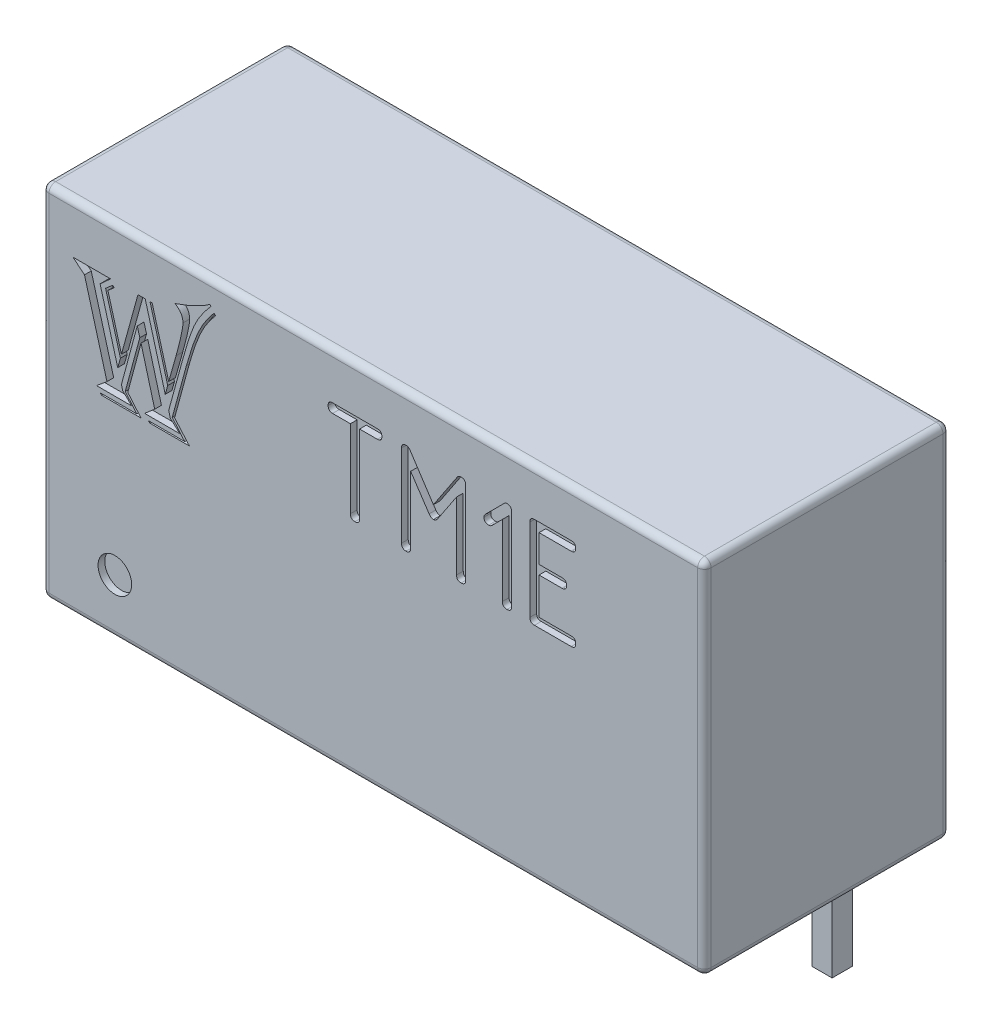
from build123d import *

# Parameters (mm, degrees)
SKETCH_2_W                         = 19.7
SKETCH_2_H                         = 7.3
EXTRUDE_1_DEPTH                    = 10.7
FILLET_1_R                         = 0.2
SKETCH_3_W                         = 0.6
SKETCH_3_H                         = 0.6
EXTRUDE_2_DEPTH                    = 4
CHAMFER_1_SIZE                     = 0.2
SKETCH_4_R                         = 0.5
CUT_EXTRUDE_1_DEPTH                = 0.2
PATTERN_LINEAR_2_COUNT             = 7
PATTERN_LINEAR_2_PITCH             = 2.54
CHAMFER_1_OF_PATTERN_LINEAR_2_SIZE = 0.2


with BuildPart() as part:
    # Эскиз2 → Бобышка-Вытянуть1 (new body)
    with BuildSketch(Plane(origin=(0, 0, 0), x_dir=(1, 0, 0), z_dir=(0, 1, 0))):
        Rectangle(SKETCH_2_W, SKETCH_2_H)
    extrude(amount=EXTRUDE_1_DEPTH)

    # Скругление1
    fillet_1_edges = [part.edges().sort_by_distance(p)[0] for p in [
        (-9.85, 10.7, 0),
        (0, 10.7, 3.65),
        (9.85, 10.7, 0),
        (0, 0, 3.65),
        (-9.85, 0, 0),
        (0, 0, -3.65),
        (9.85, 0, 0),
        (9.85, 5.35, 3.65),
        (-9.85, 5.35, 3.65),
        (-9.85, 5.35, -3.65),
        (9.85, 5.35, -3.65),
        (0, 10.7, -3.65),
    ]]
    fillet(fillet_1_edges, radius=FILLET_1_R)

    # Эскиз3 → Бобышка-Вытянуть2 (add)
    with BuildSketch(Plane.XZ):
        with Locations((-7.62, -2.38)):
            Rectangle(SKETCH_3_W, SKETCH_3_H)
    extrude_2 = extrude(amount=EXTRUDE_2_DEPTH)

    # Фаска1
    chamfer_1_edges = [part.edges().sort_by_distance(p)[0] for p in [
        (-7.32, -4, -2.38),
        (-7.62, -4, -2.08),
        (-7.92, -4, -2.38),
        (-7.62, -4, -2.68),
    ]]
    chamfer(chamfer_1_edges, length=CHAMFER_1_SIZE)

    # Эскиз4 → Вырез-Вытянуть1 (cut)
    with BuildSketch(Plane.XY.offset(3.65)):
        with Locations((-7.68950771, 1.64626856)):
            Circle(SKETCH_4_R)
        with BuildLine():
            add(Edge.make_bspline(
                [(-1.344415696, 9.182310933), (-1.344266371, 9.193129492), (-1.343986736, 9.213388959), (-1.336681075, 9.241435642), (-1.326921273, 9.26575643), (-1.311444221, 9.285324961), (-1.292475351, 9.300936794), (-1.268648064, 9.311266733), (-1.241271796, 9.318161675), (-1.221437304, 9.318538886), (-1.211035133, 9.318736714)],
                knots=[0, 0, 0, 0, 3.2331e-05, 6.0545e-05, 8.6456e-05, 0.000110333, 0.000134588, 0.000159388, 0.000187602, 0.000218717, 0.000218717, 0.000218717, 0.000218717], degree=3))
            Line((-1.211035133, 9.318736714), (0.120334321, 9.318736714))
            add(Edge.make_bspline(
                [(0.120334321, 9.318736714), (0.130736492, 9.318538886), (0.150570984, 9.318161675), (0.177947252, 9.311266733), (0.201774539, 9.300936794), (0.220743409, 9.285324961), (0.236220461, 9.26575643), (0.245980263, 9.241435642), (0.253285924, 9.213388959), (0.253565559, 9.193129492), (0.253714884, 9.182310933)],
                knots=[0, 0, 0, 0, 3.1115e-05, 5.9329e-05, 8.4128e-05, 0.000108383, 0.00013226, 0.000158172, 0.000186386, 0.000218717, 0.000218717, 0.000218717, 0.000218717], degree=3))
            add(Edge.make_bspline(
                [(0.253714884, 9.182310933), (0.253506721, 9.17171488), (0.253109537, 9.151497117), (0.246333588, 9.12341959), (0.235713285, 9.099568196), (0.22185524, 9.079051623), (0.201809069, 9.064416978), (0.178574078, 9.053182874), (0.150844395, 9.047403413), (0.131318327, 9.046411953), (0.120943365, 9.045885152)],
                knots=[0, 0, 0, 0, 3.1723e-05, 6.0529e-05, 8.5883e-05, 0.000109884, 0.000133761, 0.00015937, 0.000186852, 0.000218008, 0.000218008, 0.000218008, 0.000218008], degree=3))
            Line((0.120943365, 9.045885152), (-0.408924625, 9.045885152))
            Line((-0.408924625, 9.045885152), (-0.408924625, 6.72664687))
            add(Edge.make_bspline(
                [(-0.408924625, 6.72664687), (-0.409123847, 6.716043968), (-0.409503971, 6.695813136), (-0.416394271, 6.667823212), (-0.426740296, 6.643462653), (-0.442105441, 6.623772633), (-0.462083172, 6.60851704), (-0.485959175, 6.597567407), (-0.514423766, 6.591685723), (-0.534564433, 6.590731895), (-0.545350406, 6.590221089)],
                knots=[0, 0, 0, 0, 3.1723e-05, 6.0529e-05, 8.5883e-05, 0.000110615, 0.000134492, 0.000160653, 0.000188728, 0.000221099, 0.000221099, 0.000221099, 0.000221099], degree=3))
            add(Edge.make_bspline(
                [(-0.545350406, 6.590221089), (-0.555918226, 6.590781231), (-0.576024672, 6.591846963), (-0.604480113, 6.59725932), (-0.628120025, 6.60893511), (-0.648683127, 6.623314149), (-0.663062166, 6.643877251), (-0.674737957, 6.667517163), (-0.680150313, 6.695972604), (-0.681216045, 6.71607905), (-0.681776187, 6.72664687)],
                knots=[0, 0, 0, 0, 3.1764e-05, 6.0434e-05, 8.6043e-05, 0.000110405, 0.000134767, 0.000160375, 0.000189046, 0.00022081, 0.00022081, 0.00022081, 0.00022081], degree=3))
            Line((-0.681776187, 6.72664687), (-0.681776187, 9.045885152))
            Line((-0.681776187, 9.045885152), (-1.211644177, 9.045885152))
            add(Edge.make_bspline(
                [(-1.211644177, 9.045885152), (-1.222023494, 9.046407076), (-1.241557759, 9.047389358), (-1.269232727, 9.053230086), (-1.292506804, 9.064188778), (-1.311913095, 9.079465695), (-1.326531785, 9.099322772), (-1.336982453, 9.123461798), (-1.343825637, 9.151484696), (-1.34421279, 9.171710608), (-1.344415696, 9.182310933)],
                knots=[0, 0, 0, 0, 3.1157e-05, 5.8638e-05, 8.4247e-05, 0.000107645, 0.000132007, 0.000157361, 0.000186167, 0.00021789, 0.00021789, 0.00021789, 0.00021789], degree=3))
        make_face()
        with BuildLine():
            add(Edge.make_bspline(
                [(2.606450567, 9.318736714), (2.617669629, 9.318576919), (2.638720347, 9.318277089), (2.667824437, 9.311110872), (2.693144867, 9.301121042), (2.713485255, 9.285547476), (2.729569615, 9.265798265), (2.740193363, 9.241587062), (2.747131706, 9.213345923), (2.747930786, 9.193118581), (2.748357741, 9.182310933)],
                knots=[0, 0, 0, 0, 3.3547e-05, 6.2946e-05, 8.9416e-05, 0.000114631, 0.000138886, 0.000165047, 0.00019326, 0.000225632, 0.000225632, 0.000225632, 0.000225632], degree=3))
            Line((2.748357741, 9.182310933), (2.748357741, 6.72664687))
            add(Edge.make_bspline(
                [(2.748357741, 6.72664687), (2.748158519, 6.716043968), (2.747778395, 6.695813136), (2.740888096, 6.667823212), (2.730542071, 6.643462653), (2.715176925, 6.623772633), (2.695199194, 6.60851704), (2.671323191, 6.597567407), (2.6428586, 6.591685723), (2.622717933, 6.590731895), (2.61193196, 6.590221089)],
                knots=[0, 0, 0, 0, 3.1723e-05, 6.0529e-05, 8.5883e-05, 0.000110615, 0.000134492, 0.000160653, 0.000188728, 0.000221099, 0.000221099, 0.000221099, 0.000221099], degree=3))
            add(Edge.make_bspline(
                [(2.61193196, 6.590221089), (2.60136414, 6.590781231), (2.581257694, 6.591846963), (2.552802253, 6.59725932), (2.529162341, 6.60893511), (2.508599239, 6.623314149), (2.4942202, 6.643877251), (2.482544409, 6.667517163), (2.477132053, 6.695972604), (2.476066321, 6.71607905), (2.475506179, 6.72664687)],
                knots=[0, 0, 0, 0, 3.1764e-05, 6.0434e-05, 8.6043e-05, 0.000110405, 0.000134767, 0.000160375, 0.000189046, 0.00022081, 0.00022081, 0.00022081, 0.00022081], degree=3))
            Line((2.475506179, 6.72664687), (2.475506179, 8.735881925))
            Line((2.475506179, 8.735881925), (1.914576962, 7.892356448))
            add(Edge.make_bspline(
                [(1.914576962, 7.892356448), (1.905513698, 7.880139294), (1.888429366, 7.857109852), (1.857007015, 7.831168606), (1.823574717, 7.81407926), (1.800056553, 7.812251431), (1.788504923, 7.81135364)],
                knots=[0, 0, 0, 0, 4.5467e-05, 8.5705e-05, 0.000121395, 0.000155848, 0.000155848, 0.000155848, 0.000155848], degree=3))
            add(Edge.make_bspline(
                [(1.788504923, 7.81135364), (1.776734522, 7.812206848), (1.752708122, 7.813948464), (1.719049141, 7.831724714), (1.687150721, 7.857888061), (1.669859252, 7.881134334), (1.660605753, 7.893574535)],
                knots=[0, 0, 0, 0, 3.5056e-05, 7.1558e-05, 0.000111796, 0.000158119, 0.000158119, 0.000158119, 0.000158119], degree=3))
            Line((1.660605753, 7.893574535), (1.111248366, 8.716392528))
            Line((1.111248366, 8.716392528), (1.111248366, 6.725428783))
            add(Edge.make_bspline(
                [(1.111248366, 6.725428783), (1.111077455, 6.714815847), (1.110754539, 6.694763922), (1.103618092, 6.66708591), (1.093665514, 6.642845738), (1.07762437, 6.623854615), (1.058501648, 6.607622349), (1.033912543, 6.597997839), (1.005911146, 6.590637278), (0.985644811, 6.590365968), (0.974822585, 6.590221089)],
                knots=[0, 0, 0, 0, 3.1723e-05, 5.9937e-05, 8.5291e-05, 0.000109546, 0.000133801, 0.000159712, 0.000187926, 0.000220257, 0.000220257, 0.000220257, 0.000220257], degree=3))
            add(Edge.make_bspline(
                [(0.974822585, 6.590221089), (0.964254765, 6.590781231), (0.944148319, 6.591846963), (0.915692878, 6.59725932), (0.892052966, 6.60893511), (0.871489864, 6.623314149), (0.857110825, 6.643877251), (0.845435034, 6.667517163), (0.840022678, 6.695972604), (0.838956946, 6.71607905), (0.838396804, 6.72664687)],
                knots=[0, 0, 0, 0, 3.1764e-05, 6.0434e-05, 8.6043e-05, 0.000110405, 0.000134767, 0.000160375, 0.000189046, 0.00022081, 0.00022081, 0.00022081, 0.00022081], degree=3))
            Line((0.838396804, 6.72664687), (0.838396804, 9.182310933))
            add(Edge.make_bspline(
                [(0.838396804, 9.182310933), (0.838541683, 9.193133159), (0.838812993, 9.213399494), (0.846173553, 9.241400891), (0.855798064, 9.265989995), (0.87203033, 9.285112718), (0.891021453, 9.301153861), (0.915261625, 9.311106439), (0.942939636, 9.318242887), (0.962991562, 9.318565803), (0.973604498, 9.318736714)],
                knots=[0, 0, 0, 0, 3.2331e-05, 6.0545e-05, 8.6456e-05, 0.000110711, 0.000134966, 0.00016032, 0.000188534, 0.000220257, 0.000220257, 0.000220257, 0.000220257], degree=3))
            add(Edge.make_bspline(
                [(0.973604498, 9.318736714), (0.985504795, 9.317966788), (1.008828614, 9.316457783), (1.041867726, 9.302846556), (1.070505811, 9.280141141), (1.085290544, 9.260254006), (1.092977056, 9.24991478)],
                knots=[0, 0, 0, 0, 3.5581e-05, 6.9736e-05, 0.000105312, 0.000143836, 0.000143836, 0.000143836, 0.000143836], degree=3))
            Line((1.092977056, 9.24991478), (1.78789588, 8.193833062))
            Line((1.78789588, 8.193833062), (2.486468965, 9.243824343))
            add(Edge.make_bspline(
                [(2.486468965, 9.243824343), (2.493345007, 9.255311321), (2.50648846, 9.277268509), (2.535883061, 9.300965274), (2.569561156, 9.316159129), (2.593899291, 9.317859715), (2.606450567, 9.318736714)],
                knots=[0, 0, 0, 0, 3.9868e-05, 7.6207e-05, 0.000111395, 0.000148865, 0.000148865, 0.000148865, 0.000148865], degree=3))
        make_face()
        with BuildLine():
            Line((3.839763991, 8.840637436), (3.526106503, 8.526979948))
            add(Edge.make_bspline(
                [(3.526106503, 8.526979948), (3.519416413, 8.521200608), (3.50631719, 8.509884636), (3.483013989, 8.498055965), (3.457663496, 8.491316969), (3.440068846, 8.490331081), (3.431095691, 8.489828284)],
                knots=[0, 0, 0, 0, 2.6443e-05, 5.1775e-05, 7.7629e-05, 0.000104537, 0.000104537, 0.000104537, 0.000104537], degree=3))
            add(Edge.make_bspline(
                [(3.431095691, 8.489828284), (3.420278474, 8.489978456), (3.400021518, 8.490259678), (3.371958271, 8.497554878), (3.347426415, 8.507456612), (3.327600262, 8.523019255), (3.312540198, 8.542865576), (3.301149602, 8.566563551), (3.295671858, 8.594956541), (3.294615881, 8.615072305), (3.294060866, 8.625645022)],
                knots=[0, 0, 0, 0, 3.2331e-05, 6.0545e-05, 8.6456e-05, 0.000111188, 0.000135065, 0.000160674, 0.000189345, 0.000221108, 0.000221108, 0.000221108, 0.000221108], degree=3))
            add(Edge.make_bspline(
                [(3.294060866, 8.625645022), (3.294485372, 8.6346376), (3.29531113, 8.652130152), (3.303093367, 8.67717001), (3.315355618, 8.700296731), (3.327055034, 8.713362982), (3.333039661, 8.72004679)],
                knots=[0, 0, 0, 0, 2.6908e-05, 5.2343e-05, 7.7959e-05, 0.000104784, 0.000104784, 0.000104784, 0.000104784], degree=3))
            Line((3.333039661, 8.72004679), (3.862907651, 9.24991478))
            add(Edge.make_bspline(
                [(3.862907651, 9.24991478), (3.871726947, 9.260180566), (3.888289661, 9.279459801), (3.916257816, 9.301814324), (3.945124742, 9.316008337), (3.964890628, 9.317852819), (3.974362642, 9.318736714)],
                knots=[0, 0, 0, 0, 4.0519e-05, 7.6094e-05, 0.000106892, 0.00013523, 0.00013523, 0.00013523, 0.00013523], degree=3))
            add(Edge.make_bspline(
                [(3.974362642, 9.318736714), (3.985176023, 9.318563884), (4.00562379, 9.318237067), (4.033918963, 9.311109122), (4.058686187, 9.301135266), (4.078401278, 9.285343804), (4.094409805, 9.265810799), (4.105226825, 9.241667435), (4.111163795, 9.213248116), (4.112109238, 9.193100583), (4.112615554, 9.182310933)],
                knots=[0, 0, 0, 0, 3.2331e-05, 6.1137e-05, 8.7048e-05, 0.00011178, 0.000136035, 0.000162196, 0.000190271, 0.000222642, 0.000222642, 0.000222642, 0.000222642], degree=3))
            Line((4.112615554, 9.182310933), (4.112615554, 6.72664687))
            add(Edge.make_bspline(
                [(4.112615554, 6.72664687), (4.112416332, 6.716043968), (4.112036207, 6.695813136), (4.105145908, 6.667823212), (4.094799883, 6.643462653), (4.079434738, 6.623772633), (4.059457007, 6.60851704), (4.035581004, 6.597567407), (4.007116412, 6.591685723), (3.986975746, 6.590731895), (3.976189773, 6.590221089)],
                knots=[0, 0, 0, 0, 3.1723e-05, 6.0529e-05, 8.5883e-05, 0.000110615, 0.000134492, 0.000160653, 0.000188728, 0.000221099, 0.000221099, 0.000221099, 0.000221099], degree=3))
            add(Edge.make_bspline(
                [(3.976189773, 6.590221089), (3.965587042, 6.590420385), (3.945356538, 6.590800651), (3.917364416, 6.597690003), (3.893011037, 6.608039124), (3.87329583, 6.623393409), (3.85824547, 6.643263681), (3.846852061, 6.666954711), (3.841375179, 6.695349831), (3.840319074, 6.715465277), (3.839763991, 6.726037827)],
                knots=[0, 0, 0, 0, 3.1723e-05, 6.0529e-05, 8.5883e-05, 0.000110615, 0.000134492, 0.000160101, 0.000188771, 0.000220535, 0.000220535, 0.000220535, 0.000220535], degree=3))
            Line((3.839763991, 6.726037827), (3.839763991, 8.840637436))
        make_face()
        with BuildLine():
            Line((4.658318679, 6.72664687), (4.658318679, 9.182310933))
            add(Edge.make_bspline(
                [(4.658318679, 9.182310933), (4.658829485, 9.193096906), (4.659783313, 9.213237573), (4.665664997, 9.241702164), (4.67661463, 9.265578167), (4.691870222, 9.285555898), (4.711560243, 9.300921043), (4.735920802, 9.311267068), (4.763910726, 9.318157368), (4.784141557, 9.318537492), (4.79474446, 9.318736714)],
                knots=[0, 0, 0, 0, 3.2371e-05, 6.0447e-05, 8.6607e-05, 0.000110484, 0.000135216, 0.000160571, 0.000189376, 0.000221099, 0.000221099, 0.000221099, 0.000221099], degree=3))
            Line((4.79474446, 9.318736714), (5.88615071, 9.318736714))
            add(Edge.make_bspline(
                [(5.88615071, 9.318736714), (5.896973084, 9.318591896), (5.917239696, 9.318320701), (5.945239267, 9.310959386), (5.969834442, 9.301337384), (5.988936251, 9.285096473), (6.005177161, 9.265994664), (6.014799163, 9.24139949), (6.022160478, 9.213399919), (6.022431673, 9.193133307), (6.022576491, 9.182310933)],
                knots=[0, 0, 0, 0, 3.2331e-05, 6.0545e-05, 8.6456e-05, 0.000110711, 0.000134966, 0.000160877, 0.000189091, 0.000221422, 0.000221422, 0.000221422, 0.000221422], degree=3))
            add(Edge.make_bspline(
                [(6.022576491, 9.182310933), (6.022377269, 9.17170803), (6.021997145, 9.151477198), (6.015106846, 9.123487274), (6.004760821, 9.099126715), (5.989395675, 9.079436695), (5.969417944, 9.064181102), (5.945541941, 9.053231469), (5.91707735, 9.047349786), (5.896936683, 9.046395957), (5.88615071, 9.045885152)],
                knots=[0, 0, 0, 0, 3.1723e-05, 6.0529e-05, 8.5883e-05, 0.000110615, 0.000134492, 0.000160653, 0.000188728, 0.000221099, 0.000221099, 0.000221099, 0.000221099], degree=3))
            Line((5.88615071, 9.045885152), (4.931170241, 9.045885152))
            Line((4.931170241, 9.045885152), (4.931170241, 8.227330464))
            Line((4.931170241, 8.227330464), (5.613299148, 8.227330464))
            add(Edge.make_bspline(
                [(5.613299148, 8.227330464), (5.624121522, 8.227185646), (5.644388133, 8.226914451), (5.672387705, 8.219553136), (5.696982879, 8.209931134), (5.716084688, 8.193690223), (5.732325598, 8.174588414), (5.7419476, 8.14999324), (5.749308915, 8.121993669), (5.749580111, 8.101727057), (5.749724929, 8.090904683)],
                knots=[0, 0, 0, 0, 3.2331e-05, 6.0545e-05, 8.6456e-05, 0.000110711, 0.000134966, 0.000160877, 0.000189091, 0.000221422, 0.000221422, 0.000221422, 0.000221422], degree=3))
            add(Edge.make_bspline(
                [(5.749724929, 8.090904683), (5.749525707, 8.08030178), (5.749145582, 8.060070948), (5.742255283, 8.032081024), (5.731909258, 8.007720465), (5.716544113, 7.988030445), (5.696566382, 7.972774852), (5.672690379, 7.961825219), (5.644225787, 7.955943536), (5.624085121, 7.954989707), (5.613299148, 7.954478902)],
                knots=[0, 0, 0, 0, 3.1723e-05, 6.0529e-05, 8.5883e-05, 0.000110615, 0.000134492, 0.000160653, 0.000188728, 0.000221099, 0.000221099, 0.000221099, 0.000221099], degree=3))
            Line((5.613299148, 7.954478902), (4.931170241, 7.954478902))
            Line((4.931170241, 7.954478902), (4.931170241, 6.863072652))
            Line((4.931170241, 6.863072652), (5.88615071, 6.863072652))
            add(Edge.make_bspline(
                [(5.88615071, 6.863072652), (5.896973084, 6.862927833), (5.917239696, 6.862656638), (5.945239267, 6.855295323), (5.969834442, 6.845673321), (5.988936251, 6.829432411), (6.005177161, 6.810330602), (6.014799163, 6.785735427), (6.022160478, 6.757735856), (6.022431673, 6.737469244), (6.022576491, 6.72664687)],
                knots=[0, 0, 0, 0, 3.2331e-05, 6.0545e-05, 8.6456e-05, 0.000110711, 0.000134966, 0.000160877, 0.000189091, 0.000221422, 0.000221422, 0.000221422, 0.000221422], degree=3))
            add(Edge.make_bspline(
                [(6.022576491, 6.72664687), (6.022377269, 6.716043968), (6.021997145, 6.695813136), (6.015106846, 6.667823212), (6.004760821, 6.643462653), (5.989395675, 6.623772633), (5.969417944, 6.60851704), (5.945541941, 6.597567407), (5.91707735, 6.591685723), (5.896936683, 6.590731895), (5.88615071, 6.590221089)],
                knots=[0, 0, 0, 0, 3.1723e-05, 6.0529e-05, 8.5883e-05, 0.000110615, 0.000134492, 0.000160653, 0.000188728, 0.000221099, 0.000221099, 0.000221099, 0.000221099], degree=3))
            Line((5.88615071, 6.590221089), (4.79474446, 6.590221089))
            add(Edge.make_bspline(
                [(4.79474446, 6.590221089), (4.78417664, 6.590781231), (4.764070194, 6.591846963), (4.735614753, 6.59725932), (4.711974841, 6.60893511), (4.691411739, 6.623314149), (4.6770327, 6.643877251), (4.665356909, 6.667517163), (4.659944553, 6.695972604), (4.658878821, 6.71607905), (4.658318679, 6.72664687)],
                knots=[0, 0, 0, 0, 3.1764e-05, 6.0434e-05, 8.6043e-05, 0.000110405, 0.000134767, 0.000160375, 0.000189046, 0.00022081, 0.00022081, 0.00022081, 0.00022081], degree=3))
        make_face()
        with BuildLine():
            add(Edge.make_bspline(
                [(-4.826920529, 9.99808571), (-4.877635504, 9.940076399), (-4.976256976, 9.827270199), (-5.106321335, 9.650843506), (-5.218113707, 9.475770751), (-5.295816993, 9.325229448), (-5.351641753, 9.197924187), (-5.393852102, 9.088650364), (-5.439966404, 8.965985236), (-5.485301464, 8.828052847), (-5.534904487, 8.676531281), (-5.584495653, 8.510075747), (-5.637137079, 8.32973205), (-5.671825467, 8.204587794), (-5.689805925, 8.139720236)],
                knots=[0, 0, 0, 0, 0.000231072, 0.000449347, 0.000656859, 0.000853626, 0.000956844, 0.001073769, 0.001205006, 0.001349934, 0.001509276, 0.001683302, 0.001870948, 0.002072885, 0.002072885, 0.002072885, 0.002072885], degree=3))
            Line((-5.689805925, 8.139720236), (-6.08691, 6.690698346))
            Line((-6.08691, 6.690698346), (-6.041351827, 6.508465654))
            Line((-6.041351827, 6.508465654), (-5.758483171, 6.251435962))
            Line((-5.758483171, 6.251435962), (-6.804961204, 6.251435962))
            Line((-6.804961204, 6.251435962), (-6.504413256, 6.508465654))
            Line((-6.504413256, 6.508465654), (-6.91103695, 8.007125554))
            Line((-6.91103695, 8.007125554), (-7.305421134, 6.541104345))
            Line((-7.305421134, 6.541104345), (-6.91103695, 6.077362943))
            Line((-6.91103695, 6.077362943), (-8.083309938, 6.077362943))
            Line((-8.083309938, 6.077362943), (-8.129548084, 6.120881198))
            Line((-8.129548084, 6.120881198), (-7.036831905, 6.120881198))
            Line((-7.036831905, 6.120881198), (-7.38157808, 6.526824918))
            Line((-7.38157808, 6.526824918), (-6.947755477, 8.126800754))
            Line((-6.947755477, 8.126800754), (-7.02323245, 8.395389983))
            Line((-7.02323245, 8.395389983), (-7.49377358, 6.653299846))
            Line((-7.49377358, 6.653299846), (-7.457055053, 6.508465654))
            Line((-7.457055053, 6.508465654), (-7.188465824, 6.251435962))
            Line((-7.188465824, 6.251435962), (-8.236983775, 6.251435962))
            Line((-8.236983775, 6.251435962), (-7.924876292, 6.508465654))
            Line((-7.924876292, 6.508465654), (-8.593289486, 8.927128659))
            Line((-8.593289486, 8.927128659), (-8.937355688, 9.210677288))
            Line((-8.937355688, 9.210677288), (-7.814720709, 9.210677288))
            Line((-7.814720709, 9.210677288), (-8.129548084, 8.927128659))
            Line((-8.129548084, 8.927128659), (-7.603929163, 7.030004739))
            Line((-7.603929163, 7.030004739), (-7.52369238, 7.312873395))
            Line((-7.52369238, 7.312873395), (-7.966354628, 8.893130022))
            Line((-7.966354628, 8.893130022), (-7.757603, 9.075362714))
            Line((-7.757603, 9.075362714), (-7.704565127, 9.039324159))
            Line((-7.704565127, 9.039324159), (-7.895637464, 8.873410813))
            Line((-7.895637464, 8.873410813), (-7.49377358, 7.429828705))
            Line((-7.49377358, 7.429828705), (-7.002833268, 9.210677288))
            Line((-7.002833268, 9.210677288), (-6.78660194, 9.210677288))
            Line((-6.78660194, 9.210677288), (-6.190265855, 7.049043976))
            Line((-6.190265855, 7.049043976), (-6.1168288, 7.312873395))
            Line((-6.1168288, 7.312873395), (-6.644487639, 9.210677288))
            Line((-6.644487639, 9.210677288), (-6.580570202, 9.210677288))
            Line((-6.580570202, 9.210677288), (-6.08691, 7.429828705))
            Line((-6.08691, 7.429828705), (-5.868638753, 8.2029577))
            add(Edge.make_bspline(
                [(-5.868638753, 8.2029577), (-5.852399918, 8.260941423), (-5.821497941, 8.371282573), (-5.779709212, 8.529207611), (-5.745362849, 8.671530243), (-5.715577342, 8.797792909), (-5.6929154, 8.908429472), (-5.677234564, 9.003247309), (-5.666754945, 9.08193757), (-5.664820039, 9.129284849), (-5.663966961, 9.150159714)],
                knots=[0, 0, 0, 0, 0.000180644, 0.000343759, 0.000490044, 0.000619854, 0.000732938, 0.00082874, 0.000908189, 0.000970839, 0.000970839, 0.000970839, 0.000970839], degree=3))
            add(Edge.make_bspline(
                [(-5.663966961, 9.150159714), (-5.664444102, 9.170174469), (-5.665374575, 9.209205242), (-5.677832358, 9.265815606), (-5.696071493, 9.319093511), (-5.721278692, 9.369687349), (-5.755483305, 9.415862075), (-5.79548155, 9.459856387), (-5.843949079, 9.499529133), (-5.879944069, 9.522477437), (-5.898557553, 9.534344308)],
                knots=[0, 0, 0, 0, 5.9934e-05, 0.000116878, 0.000173003, 0.000228653, 0.000285645, 0.000344834, 0.000406648, 0.000472843, 0.000472843, 0.000472843, 0.000472843], degree=3))
            add(Edge.make_bspline(
                [(-5.898557553, 9.534344308), (-5.852854058, 9.549348083), (-5.759150323, 9.580109621), (-5.617782387, 9.635379725), (-5.471123362, 9.6968715), (-5.323941724, 9.764902592), (-5.183579625, 9.833679594), (-5.059185033, 9.901732221), (-4.953287658, 9.964804983), (-4.891923173, 10.009461396), (-4.863639056, 10.030044428)],
                knots=[0, 0, 0, 0, 0.000144284, 0.000295819, 0.000455195, 0.00062132, 0.000782187, 0.000923988, 0.00104667, 0.001151565, 0.001151565, 0.001151565, 0.001151565], degree=3))
            Line((-4.863639056, 10.030044428), (-4.826920529, 9.99808571))
        make_face()
        with BuildLine():
            add(Edge.make_bspline(
                [(-4.689566037, 9.823332718), (-4.734443021, 9.771697544), (-4.824111341, 9.66852574), (-4.94261163, 9.500409015), (-5.050747144, 9.324046548), (-5.130330435, 9.168024735), (-5.189103399, 9.034547574), (-5.233486576, 8.924608961), (-5.279663273, 8.805516723), (-5.323731783, 8.676286079), (-5.369498265, 8.538085097), (-5.415864969, 8.390388815), (-5.461873835, 8.232995082), (-5.491636742, 8.124577904), (-5.50689326, 8.069003072)],
                knots=[0, 0, 0, 0, 0.000205119, 0.000409846, 0.000616142, 0.000825366, 0.000934658, 0.001053604, 0.001181023, 0.00131779, 0.001463149, 0.001617778, 0.001782168, 0.001955059, 0.001955059, 0.001955059, 0.001955059], degree=3))
            Line((-5.50689326, 8.069003072), (-5.91283698, 6.581902709))
            Line((-5.91283698, 6.581902709), (-5.472214651, 6.077362943))
            Line((-5.472214651, 6.077362943), (-6.649247448, 6.077362943))
            Line((-6.649247448, 6.077362943), (-6.702285321, 6.120881198))
            Line((-6.702285321, 6.120881198), (-5.611609061, 6.120881198))
            Line((-5.611609061, 6.120881198), (-5.983554145, 6.558103664))
            Line((-5.983554145, 6.558103664), (-5.561291079, 8.10096179))
            add(Edge.make_bspline(
                [(-5.561291079, 8.10096179), (-5.545810979, 8.15653854), (-5.515744157, 8.26448463), (-5.469295995, 8.421058195), (-5.424003878, 8.568105942), (-5.378609024, 8.70501873), (-5.333606298, 8.831933995), (-5.289414087, 8.948917071), (-5.246347229, 9.056461553), (-5.187951552, 9.186555201), (-5.109367116, 9.341365894), (-5.001658755, 9.520549148), (-4.879052144, 9.695048433), (-4.787979013, 9.805989172), (-4.741923938, 9.862091164)],
                knots=[0, 0, 0, 0, 0.000173074, 0.00033616, 0.000489937, 0.00063465, 0.000768851, 0.00089388, 0.001009795, 0.001116325, 0.001321593, 0.001530216, 0.001743012, 0.001960709, 0.001960709, 0.001960709, 0.001960709], degree=3))
            Line((-4.741923938, 9.862091164), (-4.689566037, 9.823332718))
        make_face()
    extrude(amount=-CUT_EXTRUDE_1_DEPTH, mode=Mode.SUBTRACT)

    # Линейный массив2: Бобышка-Вытянуть2 ×7, 3 skipped
    with Locations(*[(i * PATTERN_LINEAR_2_PITCH, 0, 0) for i in range(1, PATTERN_LINEAR_2_COUNT) if i not in (2, 3, 5)]):
        add(extrude_2)

    # Фаска1 of Линейный массив2
    chamfer_1_of_pattern_linear_2_edges = [part.edges().sort_by_distance(p)[0] for p in [
        (-4.78, -4, -2.38),
        (-5.08, -4, -2.08),
        (-5.38, -4, -2.38),
        (-5.08, -4, -2.68),
        (2.84, -4, -2.38),
        (2.54, -4, -2.08),
        (2.24, -4, -2.38),
        (2.54, -4, -2.68),
        (7.92, -4, -2.38),
        (7.62, -4, -2.08),
        (7.32, -4, -2.38),
        (7.62, -4, -2.68),
    ]]
    chamfer(chamfer_1_of_pattern_linear_2_edges, length=CHAMFER_1_OF_PATTERN_LINEAR_2_SIZE)


solid = part.part
